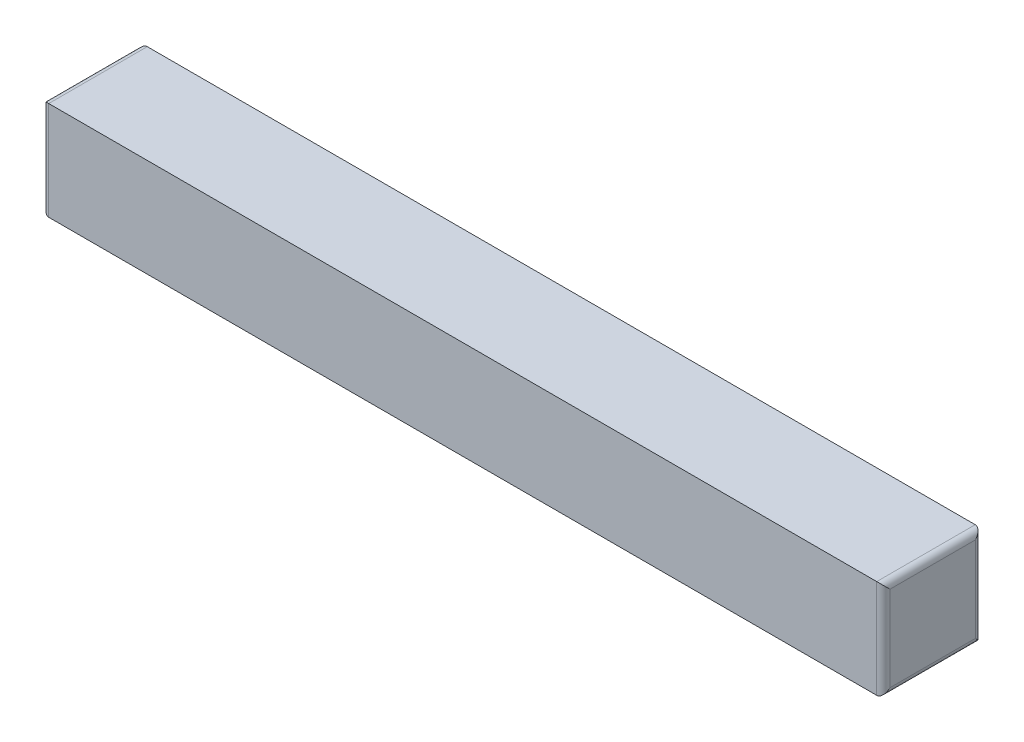
from build123d import *

# Parameters (mm, degrees)
SKETCH1_W           = 25.4
SKETCH1_H           = 2.975
BOSS_EXTRUDE1_DEPTH = 2.975
FILLET2_R           = 0.2


with BuildPart() as part:
    # Sketch1 → Boss-Extrude1 (new body)
    with BuildSketch(Plane.XY):
        with Locations((12.7, 1.4875)):
            Rectangle(SKETCH1_W, SKETCH1_H)
    extrude(amount=BOSS_EXTRUDE1_DEPTH)

    # Fillet2
    fillet2_edges = [part.edges().sort_by_distance(p)[0] for p in [
        (25.4, 1.4875, 2.975),
        (0, 1.4875, 2.975),
        (25.4, 1.4875, 0),
        (0, 1.4875, 0),
        (0, 2.975, 1.4875),
        (25.4, 2.975, 1.4875),
        (25.4, 0, 1.4875),
        (0, 0, 1.4875),
    ]]
    fillet(fillet2_edges, radius=FILLET2_R)


solid = part.part
